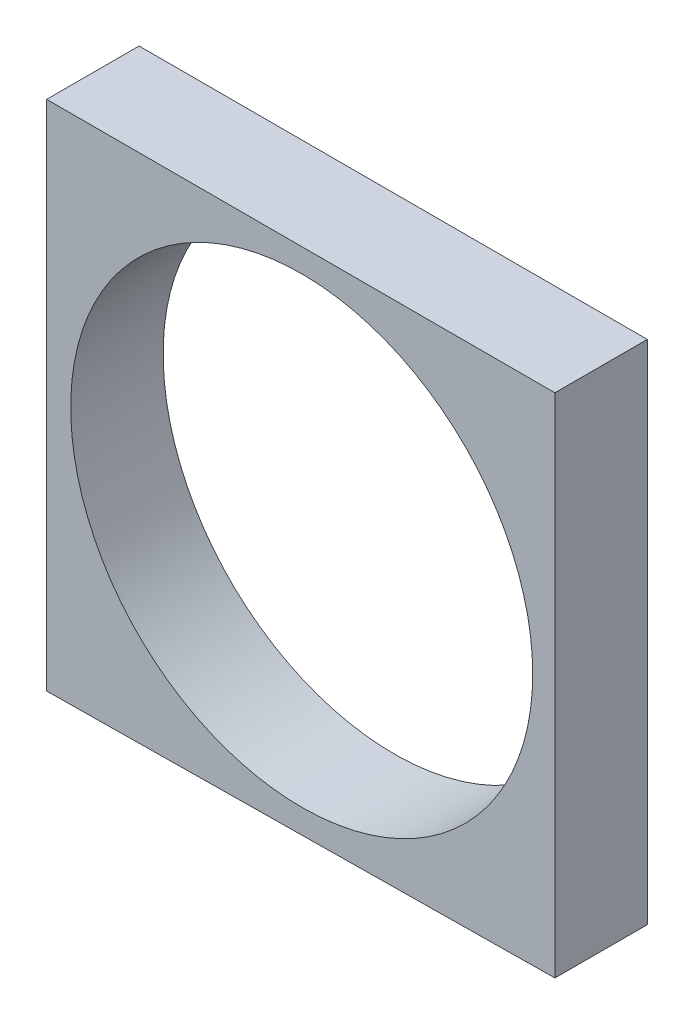
from build123d import *

# Parameters (mm, degrees)
SKETCH1_R           = 31.75
BOSS_EXTRUDE1_DEPTH = 12.7


with BuildPart() as part:
    # Sketch1 → Boss-Extrude1 (new body)
    with BuildSketch(Plane.XY):
        Polygon((-35.052, 34.9885), (34.798, 34.9885), (34.798, -34.668162611), (-35.052, -35.442967583), align=None)
        Circle(SKETCH1_R, mode=Mode.SUBTRACT)
    extrude(amount=BOSS_EXTRUDE1_DEPTH)


solid = part.part
